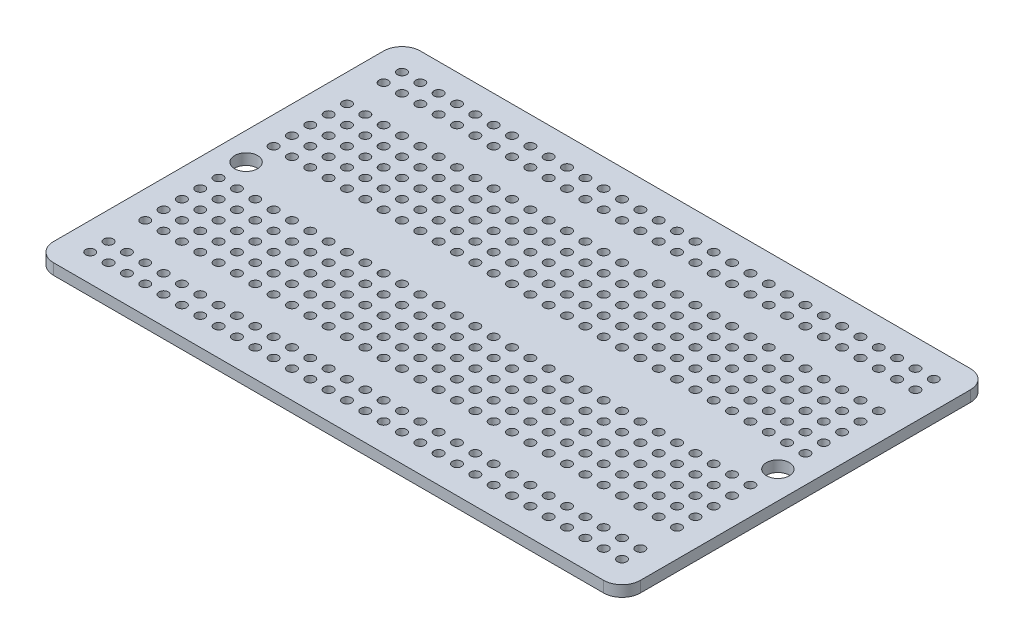
from build123d import *

# Parameters (mm, degrees)
SKETCH1_R           = 0.635
SKETCH1_R_2         = 1.5875
BOSS_EXTRUDE1_DEPTH = 1.524


with BuildPart() as part:
    # Sketch1 → Boss-Extrude1 (new body)
    with BuildSketch(Plane(origin=(0, 0, 0), x_dir=(1, 0, 0), z_dir=(0, 1, 0))):
        with BuildLine():
            Line((2.54, 0), (78.74, 0))
            ThreePointArc((78.74, 0), (80.536051224, 0.743948776), (81.28, 2.54))
            Line((81.28, 2.54), (81.28, 48.26))
            ThreePointArc((81.28, 48.26), (80.536051224, 50.056051224), (78.74, 50.8))
            Line((78.74, 50.8), (2.54, 50.8))
            ThreePointArc((2.54, 50.8), (0.743948776, 50.056051224), (0, 48.26))
            Line((0, 48.26), (0, 2.54))
            ThreePointArc((0, 2.54), (0.743948776, 0.743948776), (2.54, 0))
        make_face()
        with Locations((3.81, 46.99)):
            Circle(SKETCH1_R, mode=Mode.SUBTRACT)
        with Locations((6.35, 46.99)):
            Circle(SKETCH1_R, mode=Mode.SUBTRACT)
        with Locations((8.89, 46.99)):
            Circle(SKETCH1_R, mode=Mode.SUBTRACT)
        with Locations((11.43, 46.99)):
            Circle(SKETCH1_R, mode=Mode.SUBTRACT)
        with Locations((13.97, 46.99)):
            Circle(SKETCH1_R, mode=Mode.SUBTRACT)
        with Locations((16.51, 46.99)):
            Circle(SKETCH1_R, mode=Mode.SUBTRACT)
        with Locations((19.05, 46.99)):
            Circle(SKETCH1_R, mode=Mode.SUBTRACT)
        with Locations((21.59, 46.99)):
            Circle(SKETCH1_R, mode=Mode.SUBTRACT)
        with Locations((24.13, 46.99)):
            Circle(SKETCH1_R, mode=Mode.SUBTRACT)
        with Locations((26.67, 46.99)):
            Circle(SKETCH1_R, mode=Mode.SUBTRACT)
        with Locations((29.21, 46.99)):
            Circle(SKETCH1_R, mode=Mode.SUBTRACT)
        with Locations((31.75, 46.99)):
            Circle(SKETCH1_R, mode=Mode.SUBTRACT)
        with Locations((34.29, 46.99)):
            Circle(SKETCH1_R, mode=Mode.SUBTRACT)
        with Locations((36.83, 46.99)):
            Circle(SKETCH1_R, mode=Mode.SUBTRACT)
        with Locations((39.37, 46.99)):
            Circle(SKETCH1_R, mode=Mode.SUBTRACT)
        with Locations((41.91, 46.99)):
            Circle(SKETCH1_R, mode=Mode.SUBTRACT)
        with Locations((44.45, 46.99)):
            Circle(SKETCH1_R, mode=Mode.SUBTRACT)
        with Locations((46.99, 46.99)):
            Circle(SKETCH1_R, mode=Mode.SUBTRACT)
        with Locations((49.53, 46.99)):
            Circle(SKETCH1_R, mode=Mode.SUBTRACT)
        with Locations((52.07, 46.99)):
            Circle(SKETCH1_R, mode=Mode.SUBTRACT)
        with Locations((54.61, 46.99)):
            Circle(SKETCH1_R, mode=Mode.SUBTRACT)
        with Locations((57.15, 46.99)):
            Circle(SKETCH1_R, mode=Mode.SUBTRACT)
        with Locations((59.69, 46.99)):
            Circle(SKETCH1_R, mode=Mode.SUBTRACT)
        with Locations((62.23, 46.99)):
            Circle(SKETCH1_R, mode=Mode.SUBTRACT)
        with Locations((64.77, 46.99)):
            Circle(SKETCH1_R, mode=Mode.SUBTRACT)
        with Locations((67.31, 46.99)):
            Circle(SKETCH1_R, mode=Mode.SUBTRACT)
        with Locations((69.85, 46.99)):
            Circle(SKETCH1_R, mode=Mode.SUBTRACT)
        with Locations((72.39, 46.99)):
            Circle(SKETCH1_R, mode=Mode.SUBTRACT)
        with Locations((74.93, 46.99)):
            Circle(SKETCH1_R, mode=Mode.SUBTRACT)
        with Locations((77.47, 46.99)):
            Circle(SKETCH1_R, mode=Mode.SUBTRACT)
        with Locations((3.81, 44.45)):
            Circle(SKETCH1_R, mode=Mode.SUBTRACT)
        with Locations((6.35, 44.45)):
            Circle(SKETCH1_R, mode=Mode.SUBTRACT)
        with Locations((8.89, 44.45)):
            Circle(SKETCH1_R, mode=Mode.SUBTRACT)
        with Locations((11.43, 44.45)):
            Circle(SKETCH1_R, mode=Mode.SUBTRACT)
        with Locations((13.97, 44.45)):
            Circle(SKETCH1_R, mode=Mode.SUBTRACT)
        with Locations((16.51, 44.45)):
            Circle(SKETCH1_R, mode=Mode.SUBTRACT)
        with Locations((19.05, 44.45)):
            Circle(SKETCH1_R, mode=Mode.SUBTRACT)
        with Locations((21.59, 44.45)):
            Circle(SKETCH1_R, mode=Mode.SUBTRACT)
        with Locations((24.13, 44.45)):
            Circle(SKETCH1_R, mode=Mode.SUBTRACT)
        with Locations((26.67, 44.45)):
            Circle(SKETCH1_R, mode=Mode.SUBTRACT)
        with Locations((29.21, 44.45)):
            Circle(SKETCH1_R, mode=Mode.SUBTRACT)
        with Locations((31.75, 44.45)):
            Circle(SKETCH1_R, mode=Mode.SUBTRACT)
        with Locations((34.29, 44.45)):
            Circle(SKETCH1_R, mode=Mode.SUBTRACT)
        with Locations((36.83, 44.45)):
            Circle(SKETCH1_R, mode=Mode.SUBTRACT)
        with Locations((39.37, 44.45)):
            Circle(SKETCH1_R, mode=Mode.SUBTRACT)
        with Locations((41.91, 44.45)):
            Circle(SKETCH1_R, mode=Mode.SUBTRACT)
        with Locations((44.45, 44.45)):
            Circle(SKETCH1_R, mode=Mode.SUBTRACT)
        with Locations((46.99, 44.45)):
            Circle(SKETCH1_R, mode=Mode.SUBTRACT)
        with Locations((49.53, 44.45)):
            Circle(SKETCH1_R, mode=Mode.SUBTRACT)
        with Locations((52.07, 44.45)):
            Circle(SKETCH1_R, mode=Mode.SUBTRACT)
        with Locations((54.61, 44.45)):
            Circle(SKETCH1_R, mode=Mode.SUBTRACT)
        with Locations((57.15, 44.45)):
            Circle(SKETCH1_R, mode=Mode.SUBTRACT)
        with Locations((59.69, 44.45)):
            Circle(SKETCH1_R, mode=Mode.SUBTRACT)
        with Locations((62.23, 44.45)):
            Circle(SKETCH1_R, mode=Mode.SUBTRACT)
        with Locations((64.77, 44.45)):
            Circle(SKETCH1_R, mode=Mode.SUBTRACT)
        with Locations((67.31, 44.45)):
            Circle(SKETCH1_R, mode=Mode.SUBTRACT)
        with Locations((69.85, 44.45)):
            Circle(SKETCH1_R, mode=Mode.SUBTRACT)
        with Locations((72.39, 44.45)):
            Circle(SKETCH1_R, mode=Mode.SUBTRACT)
        with Locations((74.93, 44.45)):
            Circle(SKETCH1_R, mode=Mode.SUBTRACT)
        with Locations((77.47, 44.45)):
            Circle(SKETCH1_R, mode=Mode.SUBTRACT)
        with Locations((3.81, 39.37)):
            Circle(SKETCH1_R, mode=Mode.SUBTRACT)
        with Locations((6.35, 39.37)):
            Circle(SKETCH1_R, mode=Mode.SUBTRACT)
        with Locations((8.89, 39.37)):
            Circle(SKETCH1_R, mode=Mode.SUBTRACT)
        with Locations((11.43, 39.37)):
            Circle(SKETCH1_R, mode=Mode.SUBTRACT)
        with Locations((13.97, 39.37)):
            Circle(SKETCH1_R, mode=Mode.SUBTRACT)
        with Locations((16.51, 39.37)):
            Circle(SKETCH1_R, mode=Mode.SUBTRACT)
        with Locations((19.05, 39.37)):
            Circle(SKETCH1_R, mode=Mode.SUBTRACT)
        with Locations((21.59, 39.37)):
            Circle(SKETCH1_R, mode=Mode.SUBTRACT)
        with Locations((24.13, 39.37)):
            Circle(SKETCH1_R, mode=Mode.SUBTRACT)
        with Locations((26.67, 39.37)):
            Circle(SKETCH1_R, mode=Mode.SUBTRACT)
        with Locations((29.21, 39.37)):
            Circle(SKETCH1_R, mode=Mode.SUBTRACT)
        with Locations((31.75, 39.37)):
            Circle(SKETCH1_R, mode=Mode.SUBTRACT)
        with Locations((34.29, 39.37)):
            Circle(SKETCH1_R, mode=Mode.SUBTRACT)
        with Locations((36.83, 39.37)):
            Circle(SKETCH1_R, mode=Mode.SUBTRACT)
        with Locations((39.37, 39.37)):
            Circle(SKETCH1_R, mode=Mode.SUBTRACT)
        with Locations((41.91, 39.37)):
            Circle(SKETCH1_R, mode=Mode.SUBTRACT)
        with Locations((44.45, 39.37)):
            Circle(SKETCH1_R, mode=Mode.SUBTRACT)
        with Locations((46.99, 39.37)):
            Circle(SKETCH1_R, mode=Mode.SUBTRACT)
        with Locations((49.53, 39.37)):
            Circle(SKETCH1_R, mode=Mode.SUBTRACT)
        with Locations((52.07, 39.37)):
            Circle(SKETCH1_R, mode=Mode.SUBTRACT)
        with Locations((54.61, 39.37)):
            Circle(SKETCH1_R, mode=Mode.SUBTRACT)
        with Locations((57.15, 39.37)):
            Circle(SKETCH1_R, mode=Mode.SUBTRACT)
        with Locations((59.69, 39.37)):
            Circle(SKETCH1_R, mode=Mode.SUBTRACT)
        with Locations((62.23, 39.37)):
            Circle(SKETCH1_R, mode=Mode.SUBTRACT)
        with Locations((64.77, 39.37)):
            Circle(SKETCH1_R, mode=Mode.SUBTRACT)
        with Locations((67.31, 39.37)):
            Circle(SKETCH1_R, mode=Mode.SUBTRACT)
        with Locations((69.85, 39.37)):
            Circle(SKETCH1_R, mode=Mode.SUBTRACT)
        with Locations((72.39, 39.37)):
            Circle(SKETCH1_R, mode=Mode.SUBTRACT)
        with Locations((74.93, 39.37)):
            Circle(SKETCH1_R, mode=Mode.SUBTRACT)
        with Locations((77.47, 39.37)):
            Circle(SKETCH1_R, mode=Mode.SUBTRACT)
        with Locations((3.81, 36.83)):
            Circle(SKETCH1_R, mode=Mode.SUBTRACT)
        with Locations((6.35, 36.83)):
            Circle(SKETCH1_R, mode=Mode.SUBTRACT)
        with Locations((8.89, 36.83)):
            Circle(SKETCH1_R, mode=Mode.SUBTRACT)
        with Locations((11.43, 36.83)):
            Circle(SKETCH1_R, mode=Mode.SUBTRACT)
        with Locations((13.97, 36.83)):
            Circle(SKETCH1_R, mode=Mode.SUBTRACT)
        with Locations((16.51, 36.83)):
            Circle(SKETCH1_R, mode=Mode.SUBTRACT)
        with Locations((19.05, 36.83)):
            Circle(SKETCH1_R, mode=Mode.SUBTRACT)
        with Locations((21.59, 36.83)):
            Circle(SKETCH1_R, mode=Mode.SUBTRACT)
        with Locations((24.13, 36.83)):
            Circle(SKETCH1_R, mode=Mode.SUBTRACT)
        with Locations((26.67, 36.83)):
            Circle(SKETCH1_R, mode=Mode.SUBTRACT)
        with Locations((29.21, 36.83)):
            Circle(SKETCH1_R, mode=Mode.SUBTRACT)
        with Locations((31.75, 36.83)):
            Circle(SKETCH1_R, mode=Mode.SUBTRACT)
        with Locations((34.29, 36.83)):
            Circle(SKETCH1_R, mode=Mode.SUBTRACT)
        with Locations((36.83, 36.83)):
            Circle(SKETCH1_R, mode=Mode.SUBTRACT)
        with Locations((39.37, 36.83)):
            Circle(SKETCH1_R, mode=Mode.SUBTRACT)
        with Locations((41.91, 36.83)):
            Circle(SKETCH1_R, mode=Mode.SUBTRACT)
        with Locations((44.45, 36.83)):
            Circle(SKETCH1_R, mode=Mode.SUBTRACT)
        with Locations((46.99, 36.83)):
            Circle(SKETCH1_R, mode=Mode.SUBTRACT)
        with Locations((49.53, 36.83)):
            Circle(SKETCH1_R, mode=Mode.SUBTRACT)
        with Locations((52.07, 36.83)):
            Circle(SKETCH1_R, mode=Mode.SUBTRACT)
        with Locations((54.61, 36.83)):
            Circle(SKETCH1_R, mode=Mode.SUBTRACT)
        with Locations((57.15, 36.83)):
            Circle(SKETCH1_R, mode=Mode.SUBTRACT)
        with Locations((59.69, 36.83)):
            Circle(SKETCH1_R, mode=Mode.SUBTRACT)
        with Locations((62.23, 36.83)):
            Circle(SKETCH1_R, mode=Mode.SUBTRACT)
        with Locations((64.77, 36.83)):
            Circle(SKETCH1_R, mode=Mode.SUBTRACT)
        with Locations((67.31, 36.83)):
            Circle(SKETCH1_R, mode=Mode.SUBTRACT)
        with Locations((69.85, 36.83)):
            Circle(SKETCH1_R, mode=Mode.SUBTRACT)
        with Locations((72.39, 36.83)):
            Circle(SKETCH1_R, mode=Mode.SUBTRACT)
        with Locations((74.93, 36.83)):
            Circle(SKETCH1_R, mode=Mode.SUBTRACT)
        with Locations((77.47, 36.83)):
            Circle(SKETCH1_R, mode=Mode.SUBTRACT)
        with Locations((3.81, 34.29)):
            Circle(SKETCH1_R, mode=Mode.SUBTRACT)
        with Locations((6.35, 34.29)):
            Circle(SKETCH1_R, mode=Mode.SUBTRACT)
        with Locations((8.89, 34.29)):
            Circle(SKETCH1_R, mode=Mode.SUBTRACT)
        with Locations((11.43, 34.29)):
            Circle(SKETCH1_R, mode=Mode.SUBTRACT)
        with Locations((13.97, 34.29)):
            Circle(SKETCH1_R, mode=Mode.SUBTRACT)
        with Locations((16.51, 34.29)):
            Circle(SKETCH1_R, mode=Mode.SUBTRACT)
        with Locations((19.05, 34.29)):
            Circle(SKETCH1_R, mode=Mode.SUBTRACT)
        with Locations((21.59, 34.29)):
            Circle(SKETCH1_R, mode=Mode.SUBTRACT)
        with Locations((24.13, 34.29)):
            Circle(SKETCH1_R, mode=Mode.SUBTRACT)
        with Locations((26.67, 34.29)):
            Circle(SKETCH1_R, mode=Mode.SUBTRACT)
        with Locations((29.21, 34.29)):
            Circle(SKETCH1_R, mode=Mode.SUBTRACT)
        with Locations((31.75, 34.29)):
            Circle(SKETCH1_R, mode=Mode.SUBTRACT)
        with Locations((34.29, 34.29)):
            Circle(SKETCH1_R, mode=Mode.SUBTRACT)
        with Locations((36.83, 34.29)):
            Circle(SKETCH1_R, mode=Mode.SUBTRACT)
        with Locations((39.37, 34.29)):
            Circle(SKETCH1_R, mode=Mode.SUBTRACT)
        with Locations((41.91, 34.29)):
            Circle(SKETCH1_R, mode=Mode.SUBTRACT)
        with Locations((44.45, 34.29)):
            Circle(SKETCH1_R, mode=Mode.SUBTRACT)
        with Locations((46.99, 34.29)):
            Circle(SKETCH1_R, mode=Mode.SUBTRACT)
        with Locations((49.53, 34.29)):
            Circle(SKETCH1_R, mode=Mode.SUBTRACT)
        with Locations((52.07, 34.29)):
            Circle(SKETCH1_R, mode=Mode.SUBTRACT)
        with Locations((54.61, 34.29)):
            Circle(SKETCH1_R, mode=Mode.SUBTRACT)
        with Locations((57.15, 34.29)):
            Circle(SKETCH1_R, mode=Mode.SUBTRACT)
        with Locations((59.69, 34.29)):
            Circle(SKETCH1_R, mode=Mode.SUBTRACT)
        with Locations((62.23, 34.29)):
            Circle(SKETCH1_R, mode=Mode.SUBTRACT)
        with Locations((64.77, 34.29)):
            Circle(SKETCH1_R, mode=Mode.SUBTRACT)
        with Locations((67.31, 34.29)):
            Circle(SKETCH1_R, mode=Mode.SUBTRACT)
        with Locations((69.85, 34.29)):
            Circle(SKETCH1_R, mode=Mode.SUBTRACT)
        with Locations((72.39, 34.29)):
            Circle(SKETCH1_R, mode=Mode.SUBTRACT)
        with Locations((74.93, 34.29)):
            Circle(SKETCH1_R, mode=Mode.SUBTRACT)
        with Locations((77.47, 34.29)):
            Circle(SKETCH1_R, mode=Mode.SUBTRACT)
        with Locations((3.81, 31.75)):
            Circle(SKETCH1_R, mode=Mode.SUBTRACT)
        with Locations((6.35, 31.75)):
            Circle(SKETCH1_R, mode=Mode.SUBTRACT)
        with Locations((8.89, 31.75)):
            Circle(SKETCH1_R, mode=Mode.SUBTRACT)
        with Locations((11.43, 31.75)):
            Circle(SKETCH1_R, mode=Mode.SUBTRACT)
        with Locations((13.97, 31.75)):
            Circle(SKETCH1_R, mode=Mode.SUBTRACT)
        with Locations((16.51, 31.75)):
            Circle(SKETCH1_R, mode=Mode.SUBTRACT)
        with Locations((19.05, 31.75)):
            Circle(SKETCH1_R, mode=Mode.SUBTRACT)
        with Locations((21.59, 31.75)):
            Circle(SKETCH1_R, mode=Mode.SUBTRACT)
        with Locations((24.13, 31.75)):
            Circle(SKETCH1_R, mode=Mode.SUBTRACT)
        with Locations((26.67, 31.75)):
            Circle(SKETCH1_R, mode=Mode.SUBTRACT)
        with Locations((29.21, 31.75)):
            Circle(SKETCH1_R, mode=Mode.SUBTRACT)
        with Locations((31.75, 31.75)):
            Circle(SKETCH1_R, mode=Mode.SUBTRACT)
        with Locations((34.29, 31.75)):
            Circle(SKETCH1_R, mode=Mode.SUBTRACT)
        with Locations((36.83, 31.75)):
            Circle(SKETCH1_R, mode=Mode.SUBTRACT)
        with Locations((39.37, 31.75)):
            Circle(SKETCH1_R, mode=Mode.SUBTRACT)
        with Locations((41.91, 31.75)):
            Circle(SKETCH1_R, mode=Mode.SUBTRACT)
        with Locations((44.45, 31.75)):
            Circle(SKETCH1_R, mode=Mode.SUBTRACT)
        with Locations((46.99, 31.75)):
            Circle(SKETCH1_R, mode=Mode.SUBTRACT)
        with Locations((49.53, 31.75)):
            Circle(SKETCH1_R, mode=Mode.SUBTRACT)
        with Locations((52.07, 31.75)):
            Circle(SKETCH1_R, mode=Mode.SUBTRACT)
        with Locations((54.61, 31.75)):
            Circle(SKETCH1_R, mode=Mode.SUBTRACT)
        with Locations((57.15, 31.75)):
            Circle(SKETCH1_R, mode=Mode.SUBTRACT)
        with Locations((59.69, 31.75)):
            Circle(SKETCH1_R, mode=Mode.SUBTRACT)
        with Locations((62.23, 31.75)):
            Circle(SKETCH1_R, mode=Mode.SUBTRACT)
        with Locations((64.77, 31.75)):
            Circle(SKETCH1_R, mode=Mode.SUBTRACT)
        with Locations((67.31, 31.75)):
            Circle(SKETCH1_R, mode=Mode.SUBTRACT)
        with Locations((69.85, 31.75)):
            Circle(SKETCH1_R, mode=Mode.SUBTRACT)
        with Locations((72.39, 31.75)):
            Circle(SKETCH1_R, mode=Mode.SUBTRACT)
        with Locations((74.93, 31.75)):
            Circle(SKETCH1_R, mode=Mode.SUBTRACT)
        with Locations((77.47, 31.75)):
            Circle(SKETCH1_R, mode=Mode.SUBTRACT)
        with Locations((3.81, 29.21)):
            Circle(SKETCH1_R, mode=Mode.SUBTRACT)
        with Locations((6.35, 29.21)):
            Circle(SKETCH1_R, mode=Mode.SUBTRACT)
        with Locations((8.89, 29.21)):
            Circle(SKETCH1_R, mode=Mode.SUBTRACT)
        with Locations((11.43, 29.21)):
            Circle(SKETCH1_R, mode=Mode.SUBTRACT)
        with Locations((13.97, 29.21)):
            Circle(SKETCH1_R, mode=Mode.SUBTRACT)
        with Locations((16.51, 29.21)):
            Circle(SKETCH1_R, mode=Mode.SUBTRACT)
        with Locations((19.05, 29.21)):
            Circle(SKETCH1_R, mode=Mode.SUBTRACT)
        with Locations((21.59, 29.21)):
            Circle(SKETCH1_R, mode=Mode.SUBTRACT)
        with Locations((24.13, 29.21)):
            Circle(SKETCH1_R, mode=Mode.SUBTRACT)
        with Locations((26.67, 29.21)):
            Circle(SKETCH1_R, mode=Mode.SUBTRACT)
        with Locations((29.21, 29.21)):
            Circle(SKETCH1_R, mode=Mode.SUBTRACT)
        with Locations((31.75, 29.21)):
            Circle(SKETCH1_R, mode=Mode.SUBTRACT)
        with Locations((34.29, 29.21)):
            Circle(SKETCH1_R, mode=Mode.SUBTRACT)
        with Locations((36.83, 29.21)):
            Circle(SKETCH1_R, mode=Mode.SUBTRACT)
        with Locations((39.37, 29.21)):
            Circle(SKETCH1_R, mode=Mode.SUBTRACT)
        with Locations((41.91, 29.21)):
            Circle(SKETCH1_R, mode=Mode.SUBTRACT)
        with Locations((44.45, 29.21)):
            Circle(SKETCH1_R, mode=Mode.SUBTRACT)
        with Locations((46.99, 29.21)):
            Circle(SKETCH1_R, mode=Mode.SUBTRACT)
        with Locations((49.53, 29.21)):
            Circle(SKETCH1_R, mode=Mode.SUBTRACT)
        with Locations((52.07, 29.21)):
            Circle(SKETCH1_R, mode=Mode.SUBTRACT)
        with Locations((54.61, 29.21)):
            Circle(SKETCH1_R, mode=Mode.SUBTRACT)
        with Locations((57.15, 29.21)):
            Circle(SKETCH1_R, mode=Mode.SUBTRACT)
        with Locations((59.69, 29.21)):
            Circle(SKETCH1_R, mode=Mode.SUBTRACT)
        with Locations((62.23, 29.21)):
            Circle(SKETCH1_R, mode=Mode.SUBTRACT)
        with Locations((64.77, 29.21)):
            Circle(SKETCH1_R, mode=Mode.SUBTRACT)
        with Locations((67.31, 29.21)):
            Circle(SKETCH1_R, mode=Mode.SUBTRACT)
        with Locations((69.85, 29.21)):
            Circle(SKETCH1_R, mode=Mode.SUBTRACT)
        with Locations((72.39, 29.21)):
            Circle(SKETCH1_R, mode=Mode.SUBTRACT)
        with Locations((74.93, 29.21)):
            Circle(SKETCH1_R, mode=Mode.SUBTRACT)
        with Locations((77.47, 29.21)):
            Circle(SKETCH1_R, mode=Mode.SUBTRACT)
        with Locations((3.81, 21.59)):
            Circle(SKETCH1_R, mode=Mode.SUBTRACT)
        with Locations((6.35, 21.59)):
            Circle(SKETCH1_R, mode=Mode.SUBTRACT)
        with Locations((8.89, 21.59)):
            Circle(SKETCH1_R, mode=Mode.SUBTRACT)
        with Locations((11.43, 21.59)):
            Circle(SKETCH1_R, mode=Mode.SUBTRACT)
        with Locations((13.97, 21.59)):
            Circle(SKETCH1_R, mode=Mode.SUBTRACT)
        with Locations((16.51, 21.59)):
            Circle(SKETCH1_R, mode=Mode.SUBTRACT)
        with Locations((19.05, 21.59)):
            Circle(SKETCH1_R, mode=Mode.SUBTRACT)
        with Locations((21.59, 21.59)):
            Circle(SKETCH1_R, mode=Mode.SUBTRACT)
        with Locations((24.13, 21.59)):
            Circle(SKETCH1_R, mode=Mode.SUBTRACT)
        with Locations((26.67, 21.59)):
            Circle(SKETCH1_R, mode=Mode.SUBTRACT)
        with Locations((29.21, 21.59)):
            Circle(SKETCH1_R, mode=Mode.SUBTRACT)
        with Locations((31.75, 21.59)):
            Circle(SKETCH1_R, mode=Mode.SUBTRACT)
        with Locations((34.29, 21.59)):
            Circle(SKETCH1_R, mode=Mode.SUBTRACT)
        with Locations((36.83, 21.59)):
            Circle(SKETCH1_R, mode=Mode.SUBTRACT)
        with Locations((39.37, 21.59)):
            Circle(SKETCH1_R, mode=Mode.SUBTRACT)
        with Locations((41.91, 21.59)):
            Circle(SKETCH1_R, mode=Mode.SUBTRACT)
        with Locations((44.45, 21.59)):
            Circle(SKETCH1_R, mode=Mode.SUBTRACT)
        with Locations((46.99, 21.59)):
            Circle(SKETCH1_R, mode=Mode.SUBTRACT)
        with Locations((49.53, 21.59)):
            Circle(SKETCH1_R, mode=Mode.SUBTRACT)
        with Locations((52.07, 21.59)):
            Circle(SKETCH1_R, mode=Mode.SUBTRACT)
        with Locations((54.61, 21.59)):
            Circle(SKETCH1_R, mode=Mode.SUBTRACT)
        with Locations((57.15, 21.59)):
            Circle(SKETCH1_R, mode=Mode.SUBTRACT)
        with Locations((59.69, 21.59)):
            Circle(SKETCH1_R, mode=Mode.SUBTRACT)
        with Locations((62.23, 21.59)):
            Circle(SKETCH1_R, mode=Mode.SUBTRACT)
        with Locations((64.77, 21.59)):
            Circle(SKETCH1_R, mode=Mode.SUBTRACT)
        with Locations((67.31, 21.59)):
            Circle(SKETCH1_R, mode=Mode.SUBTRACT)
        with Locations((69.85, 21.59)):
            Circle(SKETCH1_R, mode=Mode.SUBTRACT)
        with Locations((72.39, 21.59)):
            Circle(SKETCH1_R, mode=Mode.SUBTRACT)
        with Locations((74.93, 21.59)):
            Circle(SKETCH1_R, mode=Mode.SUBTRACT)
        with Locations((77.47, 21.59)):
            Circle(SKETCH1_R, mode=Mode.SUBTRACT)
        with Locations((3.81, 19.05)):
            Circle(SKETCH1_R, mode=Mode.SUBTRACT)
        with Locations((6.35, 19.05)):
            Circle(SKETCH1_R, mode=Mode.SUBTRACT)
        with Locations((8.89, 19.05)):
            Circle(SKETCH1_R, mode=Mode.SUBTRACT)
        with Locations((11.43, 19.05)):
            Circle(SKETCH1_R, mode=Mode.SUBTRACT)
        with Locations((13.97, 19.05)):
            Circle(SKETCH1_R, mode=Mode.SUBTRACT)
        with Locations((16.51, 19.05)):
            Circle(SKETCH1_R, mode=Mode.SUBTRACT)
        with Locations((19.05, 19.05)):
            Circle(SKETCH1_R, mode=Mode.SUBTRACT)
        with Locations((21.59, 19.05)):
            Circle(SKETCH1_R, mode=Mode.SUBTRACT)
        with Locations((24.13, 19.05)):
            Circle(SKETCH1_R, mode=Mode.SUBTRACT)
        with Locations((26.67, 19.05)):
            Circle(SKETCH1_R, mode=Mode.SUBTRACT)
        with Locations((29.21, 19.05)):
            Circle(SKETCH1_R, mode=Mode.SUBTRACT)
        with Locations((31.75, 19.05)):
            Circle(SKETCH1_R, mode=Mode.SUBTRACT)
        with Locations((34.29, 19.05)):
            Circle(SKETCH1_R, mode=Mode.SUBTRACT)
        with Locations((36.83, 19.05)):
            Circle(SKETCH1_R, mode=Mode.SUBTRACT)
        with Locations((39.37, 19.05)):
            Circle(SKETCH1_R, mode=Mode.SUBTRACT)
        with Locations((41.91, 19.05)):
            Circle(SKETCH1_R, mode=Mode.SUBTRACT)
        with Locations((44.45, 19.05)):
            Circle(SKETCH1_R, mode=Mode.SUBTRACT)
        with Locations((46.99, 19.05)):
            Circle(SKETCH1_R, mode=Mode.SUBTRACT)
        with Locations((49.53, 19.05)):
            Circle(SKETCH1_R, mode=Mode.SUBTRACT)
        with Locations((52.07, 19.05)):
            Circle(SKETCH1_R, mode=Mode.SUBTRACT)
        with Locations((54.61, 19.05)):
            Circle(SKETCH1_R, mode=Mode.SUBTRACT)
        with Locations((57.15, 19.05)):
            Circle(SKETCH1_R, mode=Mode.SUBTRACT)
        with Locations((59.69, 19.05)):
            Circle(SKETCH1_R, mode=Mode.SUBTRACT)
        with Locations((62.23, 19.05)):
            Circle(SKETCH1_R, mode=Mode.SUBTRACT)
        with Locations((64.77, 19.05)):
            Circle(SKETCH1_R, mode=Mode.SUBTRACT)
        with Locations((67.31, 19.05)):
            Circle(SKETCH1_R, mode=Mode.SUBTRACT)
        with Locations((69.85, 19.05)):
            Circle(SKETCH1_R, mode=Mode.SUBTRACT)
        with Locations((72.39, 19.05)):
            Circle(SKETCH1_R, mode=Mode.SUBTRACT)
        with Locations((74.93, 19.05)):
            Circle(SKETCH1_R, mode=Mode.SUBTRACT)
        with Locations((77.47, 19.05)):
            Circle(SKETCH1_R, mode=Mode.SUBTRACT)
        with Locations((3.81, 16.51)):
            Circle(SKETCH1_R, mode=Mode.SUBTRACT)
        with Locations((6.35, 16.51)):
            Circle(SKETCH1_R, mode=Mode.SUBTRACT)
        with Locations((8.89, 16.51)):
            Circle(SKETCH1_R, mode=Mode.SUBTRACT)
        with Locations((11.43, 16.51)):
            Circle(SKETCH1_R, mode=Mode.SUBTRACT)
        with Locations((13.97, 16.51)):
            Circle(SKETCH1_R, mode=Mode.SUBTRACT)
        with Locations((16.51, 16.51)):
            Circle(SKETCH1_R, mode=Mode.SUBTRACT)
        with Locations((19.05, 16.51)):
            Circle(SKETCH1_R, mode=Mode.SUBTRACT)
        with Locations((21.59, 16.51)):
            Circle(SKETCH1_R, mode=Mode.SUBTRACT)
        with Locations((24.13, 16.51)):
            Circle(SKETCH1_R, mode=Mode.SUBTRACT)
        with Locations((26.67, 16.51)):
            Circle(SKETCH1_R, mode=Mode.SUBTRACT)
        with Locations((29.21, 16.51)):
            Circle(SKETCH1_R, mode=Mode.SUBTRACT)
        with Locations((31.75, 16.51)):
            Circle(SKETCH1_R, mode=Mode.SUBTRACT)
        with Locations((34.29, 16.51)):
            Circle(SKETCH1_R, mode=Mode.SUBTRACT)
        with Locations((36.83, 16.51)):
            Circle(SKETCH1_R, mode=Mode.SUBTRACT)
        with Locations((39.37, 16.51)):
            Circle(SKETCH1_R, mode=Mode.SUBTRACT)
        with Locations((41.91, 16.51)):
            Circle(SKETCH1_R, mode=Mode.SUBTRACT)
        with Locations((44.45, 16.51)):
            Circle(SKETCH1_R, mode=Mode.SUBTRACT)
        with Locations((46.99, 16.51)):
            Circle(SKETCH1_R, mode=Mode.SUBTRACT)
        with Locations((49.53, 16.51)):
            Circle(SKETCH1_R, mode=Mode.SUBTRACT)
        with Locations((52.07, 16.51)):
            Circle(SKETCH1_R, mode=Mode.SUBTRACT)
        with Locations((54.61, 16.51)):
            Circle(SKETCH1_R, mode=Mode.SUBTRACT)
        with Locations((57.15, 16.51)):
            Circle(SKETCH1_R, mode=Mode.SUBTRACT)
        with Locations((59.69, 16.51)):
            Circle(SKETCH1_R, mode=Mode.SUBTRACT)
        with Locations((62.23, 16.51)):
            Circle(SKETCH1_R, mode=Mode.SUBTRACT)
        with Locations((64.77, 16.51)):
            Circle(SKETCH1_R, mode=Mode.SUBTRACT)
        with Locations((67.31, 16.51)):
            Circle(SKETCH1_R, mode=Mode.SUBTRACT)
        with Locations((69.85, 16.51)):
            Circle(SKETCH1_R, mode=Mode.SUBTRACT)
        with Locations((72.39, 16.51)):
            Circle(SKETCH1_R, mode=Mode.SUBTRACT)
        with Locations((74.93, 16.51)):
            Circle(SKETCH1_R, mode=Mode.SUBTRACT)
        with Locations((77.47, 16.51)):
            Circle(SKETCH1_R, mode=Mode.SUBTRACT)
        with Locations((3.81, 13.97)):
            Circle(SKETCH1_R, mode=Mode.SUBTRACT)
        with Locations((6.35, 13.97)):
            Circle(SKETCH1_R, mode=Mode.SUBTRACT)
        with Locations((8.89, 13.97)):
            Circle(SKETCH1_R, mode=Mode.SUBTRACT)
        with Locations((11.43, 13.97)):
            Circle(SKETCH1_R, mode=Mode.SUBTRACT)
        with Locations((13.97, 13.97)):
            Circle(SKETCH1_R, mode=Mode.SUBTRACT)
        with Locations((16.51, 13.97)):
            Circle(SKETCH1_R, mode=Mode.SUBTRACT)
        with Locations((19.05, 13.97)):
            Circle(SKETCH1_R, mode=Mode.SUBTRACT)
        with Locations((21.59, 13.97)):
            Circle(SKETCH1_R, mode=Mode.SUBTRACT)
        with Locations((24.13, 13.97)):
            Circle(SKETCH1_R, mode=Mode.SUBTRACT)
        with Locations((26.67, 13.97)):
            Circle(SKETCH1_R, mode=Mode.SUBTRACT)
        with Locations((29.21, 13.97)):
            Circle(SKETCH1_R, mode=Mode.SUBTRACT)
        with Locations((31.75, 13.97)):
            Circle(SKETCH1_R, mode=Mode.SUBTRACT)
        with Locations((34.29, 13.97)):
            Circle(SKETCH1_R, mode=Mode.SUBTRACT)
        with Locations((36.83, 13.97)):
            Circle(SKETCH1_R, mode=Mode.SUBTRACT)
        with Locations((39.37, 13.97)):
            Circle(SKETCH1_R, mode=Mode.SUBTRACT)
        with Locations((41.91, 13.97)):
            Circle(SKETCH1_R, mode=Mode.SUBTRACT)
        with Locations((44.45, 13.97)):
            Circle(SKETCH1_R, mode=Mode.SUBTRACT)
        with Locations((46.99, 13.97)):
            Circle(SKETCH1_R, mode=Mode.SUBTRACT)
        with Locations((49.53, 13.97)):
            Circle(SKETCH1_R, mode=Mode.SUBTRACT)
        with Locations((52.07, 13.97)):
            Circle(SKETCH1_R, mode=Mode.SUBTRACT)
        with Locations((54.61, 13.97)):
            Circle(SKETCH1_R, mode=Mode.SUBTRACT)
        with Locations((57.15, 13.97)):
            Circle(SKETCH1_R, mode=Mode.SUBTRACT)
        with Locations((59.69, 13.97)):
            Circle(SKETCH1_R, mode=Mode.SUBTRACT)
        with Locations((62.23, 13.97)):
            Circle(SKETCH1_R, mode=Mode.SUBTRACT)
        with Locations((64.77, 13.97)):
            Circle(SKETCH1_R, mode=Mode.SUBTRACT)
        with Locations((67.31, 13.97)):
            Circle(SKETCH1_R, mode=Mode.SUBTRACT)
        with Locations((69.85, 13.97)):
            Circle(SKETCH1_R, mode=Mode.SUBTRACT)
        with Locations((72.39, 13.97)):
            Circle(SKETCH1_R, mode=Mode.SUBTRACT)
        with Locations((74.93, 13.97)):
            Circle(SKETCH1_R, mode=Mode.SUBTRACT)
        with Locations((77.47, 13.97)):
            Circle(SKETCH1_R, mode=Mode.SUBTRACT)
        with Locations((3.81, 11.43)):
            Circle(SKETCH1_R, mode=Mode.SUBTRACT)
        with Locations((6.35, 11.43)):
            Circle(SKETCH1_R, mode=Mode.SUBTRACT)
        with Locations((8.89, 11.43)):
            Circle(SKETCH1_R, mode=Mode.SUBTRACT)
        with Locations((11.43, 11.43)):
            Circle(SKETCH1_R, mode=Mode.SUBTRACT)
        with Locations((13.97, 11.43)):
            Circle(SKETCH1_R, mode=Mode.SUBTRACT)
        with Locations((16.51, 11.43)):
            Circle(SKETCH1_R, mode=Mode.SUBTRACT)
        with Locations((19.05, 11.43)):
            Circle(SKETCH1_R, mode=Mode.SUBTRACT)
        with Locations((21.59, 11.43)):
            Circle(SKETCH1_R, mode=Mode.SUBTRACT)
        with Locations((24.13, 11.43)):
            Circle(SKETCH1_R, mode=Mode.SUBTRACT)
        with Locations((26.67, 11.43)):
            Circle(SKETCH1_R, mode=Mode.SUBTRACT)
        with Locations((29.21, 11.43)):
            Circle(SKETCH1_R, mode=Mode.SUBTRACT)
        with Locations((31.75, 11.43)):
            Circle(SKETCH1_R, mode=Mode.SUBTRACT)
        with Locations((34.29, 11.43)):
            Circle(SKETCH1_R, mode=Mode.SUBTRACT)
        with Locations((36.83, 11.43)):
            Circle(SKETCH1_R, mode=Mode.SUBTRACT)
        with Locations((39.37, 11.43)):
            Circle(SKETCH1_R, mode=Mode.SUBTRACT)
        with Locations((41.91, 11.43)):
            Circle(SKETCH1_R, mode=Mode.SUBTRACT)
        with Locations((44.45, 11.43)):
            Circle(SKETCH1_R, mode=Mode.SUBTRACT)
        with Locations((46.99, 11.43)):
            Circle(SKETCH1_R, mode=Mode.SUBTRACT)
        with Locations((49.53, 11.43)):
            Circle(SKETCH1_R, mode=Mode.SUBTRACT)
        with Locations((52.07, 11.43)):
            Circle(SKETCH1_R, mode=Mode.SUBTRACT)
        with Locations((54.61, 11.43)):
            Circle(SKETCH1_R, mode=Mode.SUBTRACT)
        with Locations((57.15, 11.43)):
            Circle(SKETCH1_R, mode=Mode.SUBTRACT)
        with Locations((59.69, 11.43)):
            Circle(SKETCH1_R, mode=Mode.SUBTRACT)
        with Locations((62.23, 11.43)):
            Circle(SKETCH1_R, mode=Mode.SUBTRACT)
        with Locations((64.77, 11.43)):
            Circle(SKETCH1_R, mode=Mode.SUBTRACT)
        with Locations((67.31, 11.43)):
            Circle(SKETCH1_R, mode=Mode.SUBTRACT)
        with Locations((69.85, 11.43)):
            Circle(SKETCH1_R, mode=Mode.SUBTRACT)
        with Locations((72.39, 11.43)):
            Circle(SKETCH1_R, mode=Mode.SUBTRACT)
        with Locations((74.93, 11.43)):
            Circle(SKETCH1_R, mode=Mode.SUBTRACT)
        with Locations((77.47, 11.43)):
            Circle(SKETCH1_R, mode=Mode.SUBTRACT)
        with Locations((3.81, 6.35)):
            Circle(SKETCH1_R, mode=Mode.SUBTRACT)
        with Locations((6.35, 6.35)):
            Circle(SKETCH1_R, mode=Mode.SUBTRACT)
        with Locations((8.89, 6.35)):
            Circle(SKETCH1_R, mode=Mode.SUBTRACT)
        with Locations((11.43, 6.35)):
            Circle(SKETCH1_R, mode=Mode.SUBTRACT)
        with Locations((13.97, 6.35)):
            Circle(SKETCH1_R, mode=Mode.SUBTRACT)
        with Locations((16.51, 6.35)):
            Circle(SKETCH1_R, mode=Mode.SUBTRACT)
        with Locations((19.05, 6.35)):
            Circle(SKETCH1_R, mode=Mode.SUBTRACT)
        with Locations((21.59, 6.35)):
            Circle(SKETCH1_R, mode=Mode.SUBTRACT)
        with Locations((24.13, 6.35)):
            Circle(SKETCH1_R, mode=Mode.SUBTRACT)
        with Locations((26.67, 6.35)):
            Circle(SKETCH1_R, mode=Mode.SUBTRACT)
        with Locations((29.21, 6.35)):
            Circle(SKETCH1_R, mode=Mode.SUBTRACT)
        with Locations((31.75, 6.35)):
            Circle(SKETCH1_R, mode=Mode.SUBTRACT)
        with Locations((34.29, 6.35)):
            Circle(SKETCH1_R, mode=Mode.SUBTRACT)
        with Locations((36.83, 6.35)):
            Circle(SKETCH1_R, mode=Mode.SUBTRACT)
        with Locations((39.37, 6.35)):
            Circle(SKETCH1_R, mode=Mode.SUBTRACT)
        with Locations((41.91, 6.35)):
            Circle(SKETCH1_R, mode=Mode.SUBTRACT)
        with Locations((44.45, 6.35)):
            Circle(SKETCH1_R, mode=Mode.SUBTRACT)
        with Locations((46.99, 6.35)):
            Circle(SKETCH1_R, mode=Mode.SUBTRACT)
        with Locations((49.53, 6.35)):
            Circle(SKETCH1_R, mode=Mode.SUBTRACT)
        with Locations((52.07, 6.35)):
            Circle(SKETCH1_R, mode=Mode.SUBTRACT)
        with Locations((54.61, 6.35)):
            Circle(SKETCH1_R, mode=Mode.SUBTRACT)
        with Locations((57.15, 6.35)):
            Circle(SKETCH1_R, mode=Mode.SUBTRACT)
        with Locations((59.69, 6.35)):
            Circle(SKETCH1_R, mode=Mode.SUBTRACT)
        with Locations((62.23, 6.35)):
            Circle(SKETCH1_R, mode=Mode.SUBTRACT)
        with Locations((64.77, 6.35)):
            Circle(SKETCH1_R, mode=Mode.SUBTRACT)
        with Locations((67.31, 6.35)):
            Circle(SKETCH1_R, mode=Mode.SUBTRACT)
        with Locations((69.85, 6.35)):
            Circle(SKETCH1_R, mode=Mode.SUBTRACT)
        with Locations((72.39, 6.35)):
            Circle(SKETCH1_R, mode=Mode.SUBTRACT)
        with Locations((74.93, 6.35)):
            Circle(SKETCH1_R, mode=Mode.SUBTRACT)
        with Locations((77.47, 6.35)):
            Circle(SKETCH1_R, mode=Mode.SUBTRACT)
        with Locations((3.81, 3.81)):
            Circle(SKETCH1_R, mode=Mode.SUBTRACT)
        with Locations((6.35, 3.81)):
            Circle(SKETCH1_R, mode=Mode.SUBTRACT)
        with Locations((8.89, 3.81)):
            Circle(SKETCH1_R, mode=Mode.SUBTRACT)
        with Locations((11.43, 3.81)):
            Circle(SKETCH1_R, mode=Mode.SUBTRACT)
        with Locations((13.97, 3.81)):
            Circle(SKETCH1_R, mode=Mode.SUBTRACT)
        with Locations((16.51, 3.81)):
            Circle(SKETCH1_R, mode=Mode.SUBTRACT)
        with Locations((19.05, 3.81)):
            Circle(SKETCH1_R, mode=Mode.SUBTRACT)
        with Locations((21.59, 3.81)):
            Circle(SKETCH1_R, mode=Mode.SUBTRACT)
        with Locations((24.13, 3.81)):
            Circle(SKETCH1_R, mode=Mode.SUBTRACT)
        with Locations((26.67, 3.81)):
            Circle(SKETCH1_R, mode=Mode.SUBTRACT)
        with Locations((29.21, 3.81)):
            Circle(SKETCH1_R, mode=Mode.SUBTRACT)
        with Locations((31.75, 3.81)):
            Circle(SKETCH1_R, mode=Mode.SUBTRACT)
        with Locations((34.29, 3.81)):
            Circle(SKETCH1_R, mode=Mode.SUBTRACT)
        with Locations((36.83, 3.81)):
            Circle(SKETCH1_R, mode=Mode.SUBTRACT)
        with Locations((39.37, 3.81)):
            Circle(SKETCH1_R, mode=Mode.SUBTRACT)
        with Locations((41.91, 3.81)):
            Circle(SKETCH1_R, mode=Mode.SUBTRACT)
        with Locations((44.45, 3.81)):
            Circle(SKETCH1_R, mode=Mode.SUBTRACT)
        with Locations((46.99, 3.81)):
            Circle(SKETCH1_R, mode=Mode.SUBTRACT)
        with Locations((49.53, 3.81)):
            Circle(SKETCH1_R, mode=Mode.SUBTRACT)
        with Locations((52.07, 3.81)):
            Circle(SKETCH1_R, mode=Mode.SUBTRACT)
        with Locations((54.61, 3.81)):
            Circle(SKETCH1_R, mode=Mode.SUBTRACT)
        with Locations((57.15, 3.81)):
            Circle(SKETCH1_R, mode=Mode.SUBTRACT)
        with Locations((59.69, 3.81)):
            Circle(SKETCH1_R, mode=Mode.SUBTRACT)
        with Locations((62.23, 3.81)):
            Circle(SKETCH1_R, mode=Mode.SUBTRACT)
        with Locations((64.77, 3.81)):
            Circle(SKETCH1_R, mode=Mode.SUBTRACT)
        with Locations((67.31, 3.81)):
            Circle(SKETCH1_R, mode=Mode.SUBTRACT)
        with Locations((69.85, 3.81)):
            Circle(SKETCH1_R, mode=Mode.SUBTRACT)
        with Locations((72.39, 3.81)):
            Circle(SKETCH1_R, mode=Mode.SUBTRACT)
        with Locations((74.93, 3.81)):
            Circle(SKETCH1_R, mode=Mode.SUBTRACT)
        with Locations((77.47, 3.81)):
            Circle(SKETCH1_R, mode=Mode.SUBTRACT)
        with Locations((3.81, 25.4)):
            Circle(SKETCH1_R_2, mode=Mode.SUBTRACT)
        with Locations((77.47, 25.4)):
            Circle(SKETCH1_R_2, mode=Mode.SUBTRACT)
    extrude(amount=BOSS_EXTRUDE1_DEPTH)


solid = part.part
